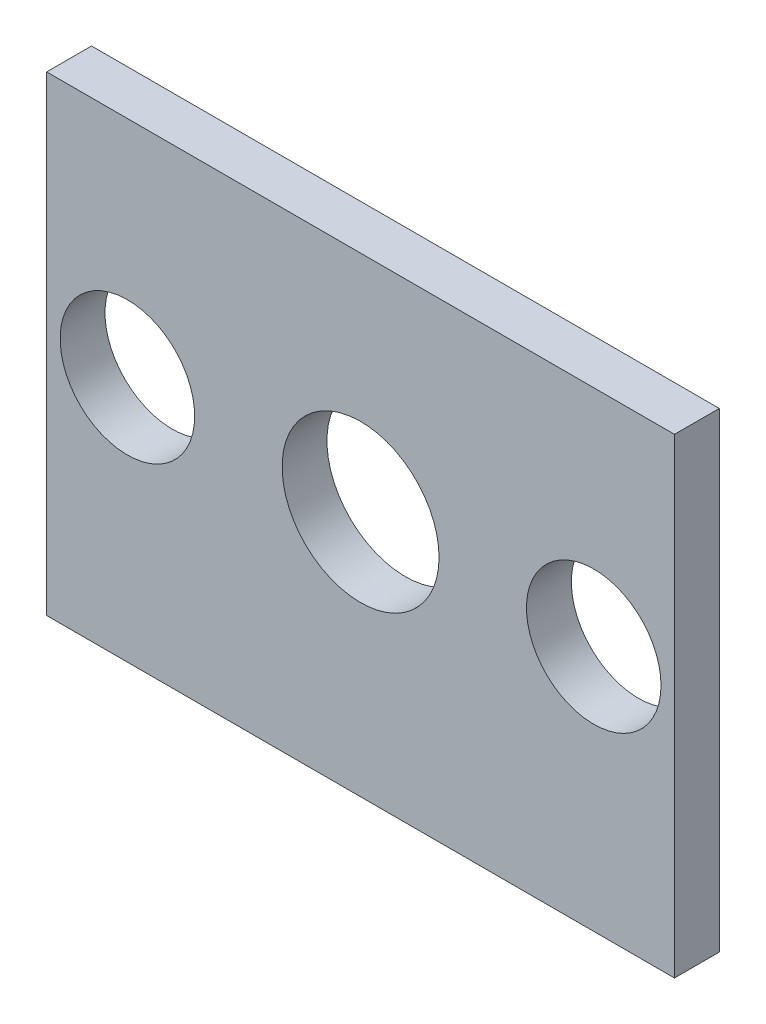
from build123d import *

# Parameters (mm, degrees)
SKETCH1_W           = 88.9
SKETCH1_H           = 66.675
SKETCH1_R           = 9.525
SKETCH1_R_2         = 11.1125
BOSS_EXTRUDE1_DEPTH = 6.35


with BuildPart() as part:
    # Sketch1 → Boss-Extrude1 (new body)
    with BuildSketch(Plane.XY):
        with Locations((0, -1.5875)):
            Rectangle(SKETCH1_W, SKETCH1_H)
        with Locations((-33.02, 0)):
            Circle(SKETCH1_R, mode=Mode.SUBTRACT)
        Circle(SKETCH1_R_2, mode=Mode.SUBTRACT)
        with Locations((33.02, 0)):
            Circle(SKETCH1_R, mode=Mode.SUBTRACT)
    extrude(amount=BOSS_EXTRUDE1_DEPTH)


solid = part.part
